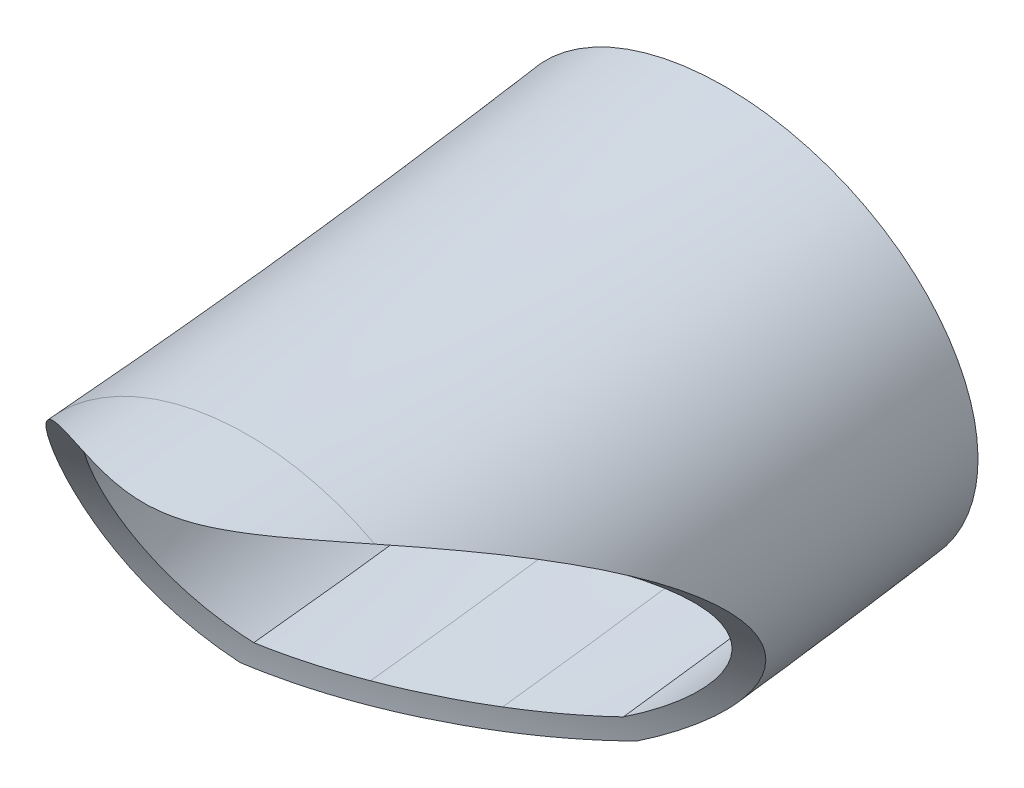
from build123d import *

# Parameters (mm, degrees)
SKETCH3_R          = 16.25
CUT_EXTRUDE1_DEPTH = 45.834177431


with BuildPart() as part:
    # Sweep1: sweep along a path in Sketch2
    with BuildLine(Plane(origin=(-698.379058796, 41.4364759, 0), x_dir=(0, 0, -1), z_dir=(0.998244469, -0.059228198, 0))) as sweep1_path:
        Line((0, 6.876622715), (7.659645623, 7.559094399))
        ThreePointArc((7.659645623, 7.559094399), (18.698398573, 8.790360973), (29.671566468, 10.510730238))
    # Sketch1 → Sweep1 (sweep)
    with BuildSketch(Plane.XY):
        with BuildLine():
            add(Edge.make_bspline(
                [(-692.93252564, 39.362944853), (-691.957016136, 39.825384184), (-690.099496797, 41.04652039), (-688.112814911, 43.510739527), (-687.098422608, 46.426504452), (-687.23500655, 49.470891985), (-688.507093379, 52.266864668), (-691.467061069, 55.256574495), (-696.886380076, 57.100375178), (-703.763947402, 55.678990023), (-707.770095003, 51.823405631), (-708.937878005, 47.886986943), (-708.659300241, 44.853532621), (-707.490459885, 42.567187528), (-706.100799961, 41.033164526), (-705.267027784, 40.373793361), (-704.830807668, 40.080908592)],
                knots=[1.995535704, 1.995535704, 1.995535704, 1.995535704, 2.313580796, 2.631625887, 2.949670979, 3.26771607, 3.585761162, 3.903806253, 4.539896436, 5.175986619, 5.812076802, 6.130121893, 6.448166984, 6.766212076, 6.925234621, 7.084257167, 7.084257167, 7.084257167, 7.084257167], degree=3))
            add(Edge.make_bspline(
                [(-704.830807668, 40.080908592), (-704.728551324, 40.045111043), (-704.533670826, 39.976124264), (-704.064780431, 39.823225537), (-703.546416047, 39.673360316), (-702.932072373, 39.52051458), (-702.409285452, 39.404772658), (-701.905118579, 39.307533961), (-701.451563284, 39.230587092), (-701.184064604, 39.18987892), (-701.055168819, 39.171407628)],
                knots=[-0.074722535, -0.074722535, -0.074722535, -0.074722535, 0.05959777, 0.193918075, 0.462558686, 0.596878991, 0.731199296, 0.865519601, 0.932679753, 0.999839906, 0.999839906, 0.999839906, 0.999839906], degree=3))
            add(Edge.make_bspline(
                [(-701.055168819, 39.171407628), (-700.911863603, 39.150661603), (-700.637894779, 39.113556304), (-699.984198678, 39.037323237), (-698.998718065, 38.95450437), (-698.004672235, 38.920623684), (-697.350655872, 38.918561231), (-697.070394641, 38.92271226), (-696.924457907, 38.926119025)],
                knots=[0.000300399, 0.000300399, 0.000300399, 0.000300399, 0.125226425, 0.25015245, 0.5000045, 0.74985655, 0.874782576, 0.999708601, 0.999708601, 0.999708601, 0.999708601], degree=3))
            add(Edge.make_bspline(
                [(-696.924457907, 38.926119025), (-696.792617771, 38.929010912), (-696.519002039, 38.937262894), (-696.051895728, 38.958829204), (-695.529527029, 38.993876678), (-694.981120223, 39.044487739), (-694.329058885, 39.12017353), (-693.77116624, 39.204105963), (-693.263172106, 39.295849162), (-693.045726915, 39.340147508), (-692.93252564, 39.362944853)],
                knots=[0.000153613, 0.000153613, 0.000153613, 0.000153613, 0.066779663, 0.133405713, 0.266657813, 0.399909912, 0.533162012, 0.799666212, 0.932918312, 1.066170412, 1.066170412, 1.066170412, 1.066170412], degree=3))
        make_face()
        with BuildLine():
            add(Edge.make_bspline(
                [(-693.252805441, 40.3185214), (-692.807908938, 40.535480383), (-691.940047311, 41.0361462), (-690.420040691, 42.23898711), (-688.958885387, 44.088290241), (-688.105700735, 46.642925498), (-688.287690032, 50.156551266), (-691.00519699, 54.024997434), (-696.935818255, 56.050608121), (-703.260819747, 54.749126331), (-706.863260958, 51.284892253), (-707.90832638, 47.855953826), (-707.698789865, 45.228672428), (-706.707903058, 43.219926419), (-705.499773096, 41.847812294), (-704.761937497, 41.247809632), (-704.376459746, 40.981358334)],
                knots=[2.008162381, 2.008162381, 2.008162381, 2.008162381, 2.166358551, 2.324554721, 2.640947061, 2.957339402, 3.273731742, 3.906516423, 4.539301103, 5.172085784, 5.804870464, 6.121262805, 6.437655145, 6.754047485, 6.912243656, 7.070439826, 7.070439826, 7.070439826, 7.070439826], degree=3))
            add(Edge.make_bspline(
                [(-704.376459746, 40.981358334), (-704.175717836, 40.911083296), (-703.796566175, 40.785202497), (-703.069638745, 40.579759647), (-702.333030237, 40.407645389), (-701.686973727, 40.284535002), (-701.272684987, 40.214818753), (-701.029786751, 40.17798247), (-700.912603361, 40.161193275)],
                knots=[-0.017712149, -0.017712149, -0.017712149, -0.017712149, 0.23670625, 0.491124649, 0.745543048, 0.872752248, 0.936356847, 0.999961447, 0.999961447, 0.999961447, 0.999961447], degree=3))
            add(Edge.make_bspline(
                [(-700.912603361, 40.161193275), (-700.77554758, 40.141347302), (-700.513765785, 40.105884003), (-699.887136098, 40.032779941), (-698.93988661, 39.953142875), (-697.983657051, 39.920566649), (-697.355577939, 39.918603881), (-697.087020253, 39.922592443), (-696.947091949, 39.9258631)],
                knots=[7.249e-05, 7.249e-05, 7.249e-05, 7.249e-05, 0.125054672, 0.250036855, 0.500001221, 0.749965586, 0.874947769, 0.999929952, 0.999929952, 0.999929952, 0.999929952], degree=3))
            add(Edge.make_bspline(
                [(-696.947091949, 39.9258631), (-696.826195995, 39.928511532), (-696.575603803, 39.935958999), (-696.145377993, 39.955340265), (-695.470410761, 39.99937565), (-694.684884982, 40.080578019), (-693.896110219, 40.195329615), (-693.475240652, 40.273725683), (-693.252805441, 40.3185214)],
                knots=[3.6878e-05, 3.6878e-05, 3.6878e-05, 3.6878e-05, 0.063510997, 0.126985115, 0.253933351, 0.507829824, 0.761726297, 1.01562277, 1.01562277, 1.01562277, 1.01562277], degree=3))
        make_face(mode=Mode.SUBTRACT)
    sweep(path=sweep1_path.line)

    # Sketch3 → Cut-Extrude1 (cut, through all)
    with BuildSketch(Plane(origin=(-577.67574675, 56.502673607, 287.106584899), x_dir=(0.441262072, -0.043160003, 0.896339778), z_dir=(-0.892082717, 0.087254933, 0.443367796))):
        with Locations((-309.438132598, -27.232444385)):
            Circle(SKETCH3_R)
    extrude(amount=-CUT_EXTRUDE1_DEPTH, mode=Mode.SUBTRACT)


solid = part.part
